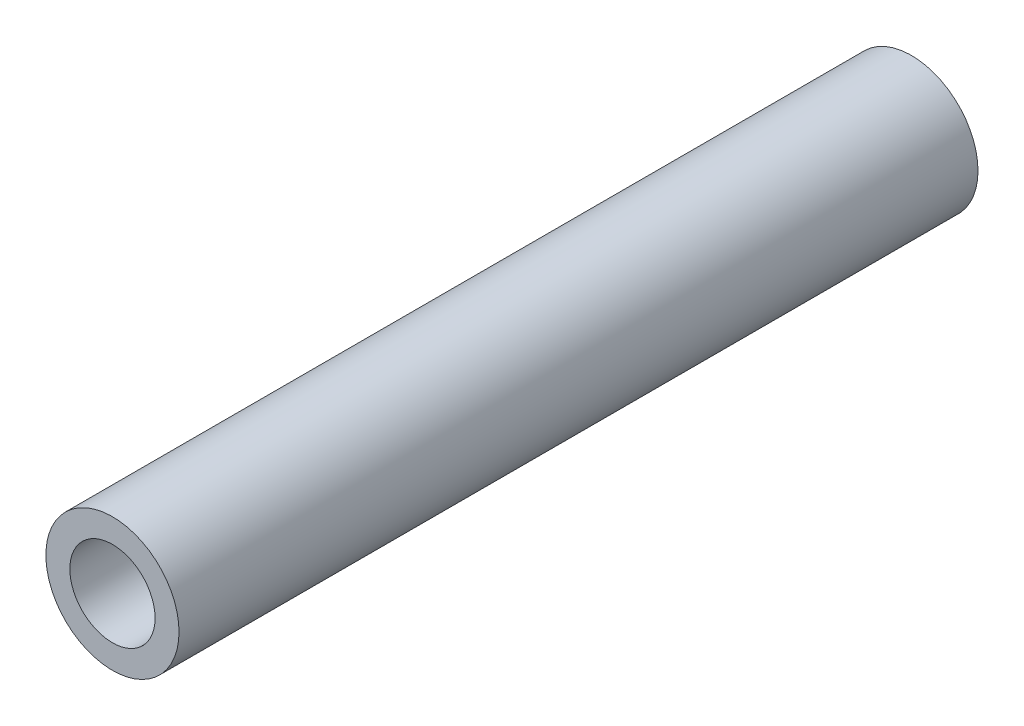
from build123d import *

# Parameters (mm, degrees)
SKETCH1_R           = 2.5
SKETCH1_R_2         = 1.6
BOSS_EXTRUDE4_DEPTH = 30


with BuildPart() as part:
    # Sketch1 → Boss-Extrude4 (new body)
    with BuildSketch(Plane.XY):
        Circle(SKETCH1_R)
        Circle(SKETCH1_R_2, mode=Mode.SUBTRACT)
    extrude(amount=BOSS_EXTRUDE4_DEPTH)


solid = part.part
